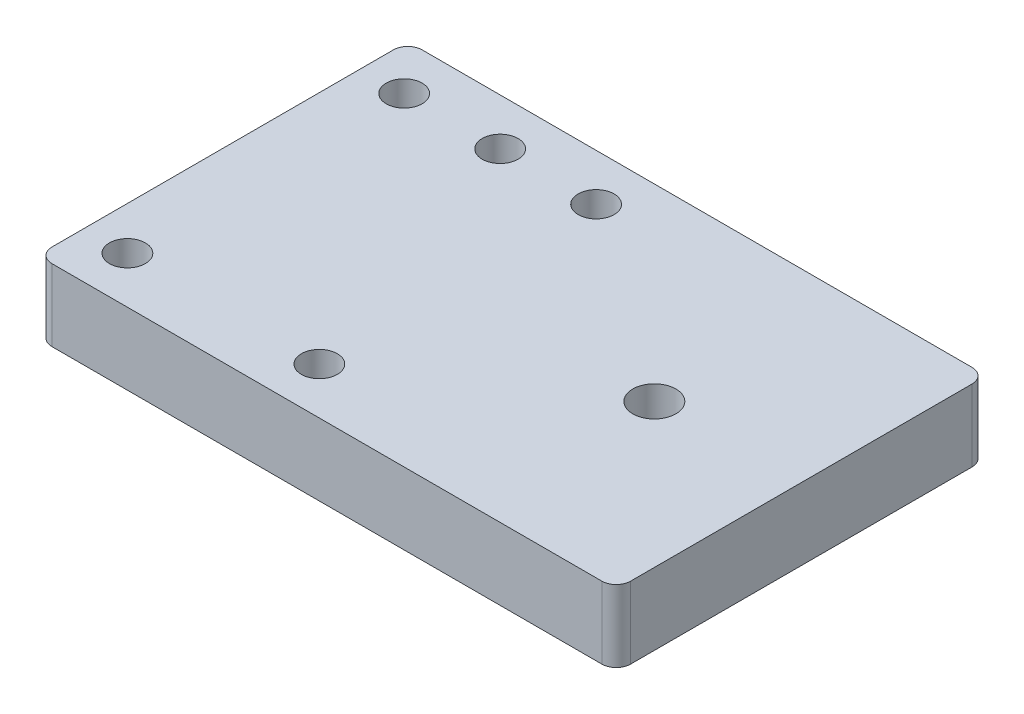
from build123d import *

# Parameters (mm, degrees)
SKETCH1_W               = 80.5
SKETCH1_H               = 51.5
BOSS_EXTRUDE1_DEPTH     = 10
SKETCH2_R               = 2.5
CUT_EXTRUDE1_DEPTH      = 11
MIRROR2_COPY_1_SKETCH_R = 2.5
MIRROR2_COPY_1_DEPTH    = 11
SKETCH3_R               = 2.5
CUT_EXTRUDE2_DEPTH      = 11
SKETCH4_R               = 3
CUT_EXTRUDE3_DEPTH      = 11
FILLET1_R               = 2


with BuildPart() as part:
    # Sketch1 → Boss-Extrude1 (new body)
    with BuildSketch(Plane(origin=(0, 0, 0), x_dir=(1, 0, 0), z_dir=(0, 1, 0))):
        Rectangle(SKETCH1_W, SKETCH1_H)
    extrude(amount=BOSS_EXTRUDE1_DEPTH)

    # Sketch2 → Cut-Extrude1 (cut, through all)
    with BuildSketch(Plane(origin=(0, 10, 0), x_dir=(1, 0, 0), z_dir=(0, 1, 0))):
        with Locations((-34.25, 19.25)):
            Circle(SKETCH2_R)
    cut_extrude1 = extrude(amount=-CUT_EXTRUDE1_DEPTH, mode=Mode.SUBTRACT)

    # Mirror1: Cut-Extrude1 across plane
    add(cut_extrude1.mirror(Plane.ZY.offset(20.9)), mode=Mode.SUBTRACT)

    # Mirror2: Cut-Extrude1 across plane
    add(cut_extrude1.mirror(Plane.XY), mode=Mode.SUBTRACT)

    # Mirror2 copy 1 sketch → Mirror2 copy 1 (cut, through all)
    with BuildSketch(Plane(origin=(-41.8, 10, 0), x_dir=(-1, 0, 0), z_dir=(0, 1, 0))):
        with Locations((-34.25, 19.25)):
            Circle(MIRROR2_COPY_1_SKETCH_R)
    extrude(amount=-MIRROR2_COPY_1_DEPTH, mode=Mode.SUBTRACT)

    # Sketch3 → Cut-Extrude2 (cut, through all)
    with BuildSketch(Plane(origin=(0, 10, 0), x_dir=(1, 0, 0), z_dir=(0, 1, 0))):
        with Locations((-20.9, 19.25)):
            Circle(SKETCH3_R)
    extrude(amount=-CUT_EXTRUDE2_DEPTH, mode=Mode.SUBTRACT)

    # Sketch4 → Cut-Extrude3 (cut, through all)
    with BuildSketch(Plane(origin=(0, 10, 0), x_dir=(1, 0, 0), z_dir=(0, 1, 0))):
        with Locations((20.25, -0.45)):
            Circle(SKETCH4_R)
    extrude(amount=-CUT_EXTRUDE3_DEPTH, mode=Mode.SUBTRACT)

    # Fillet1
    fillet1_edges = [part.edges().sort_by_distance(p)[0] for p in [
        (40.25, 5, 25.75),
        (-40.25, 5, 25.75),
        (-40.25, 5, -25.75),
        (40.25, 5, -25.75),
    ]]
    fillet(fillet1_edges, radius=FILLET1_R)


solid = part.part
